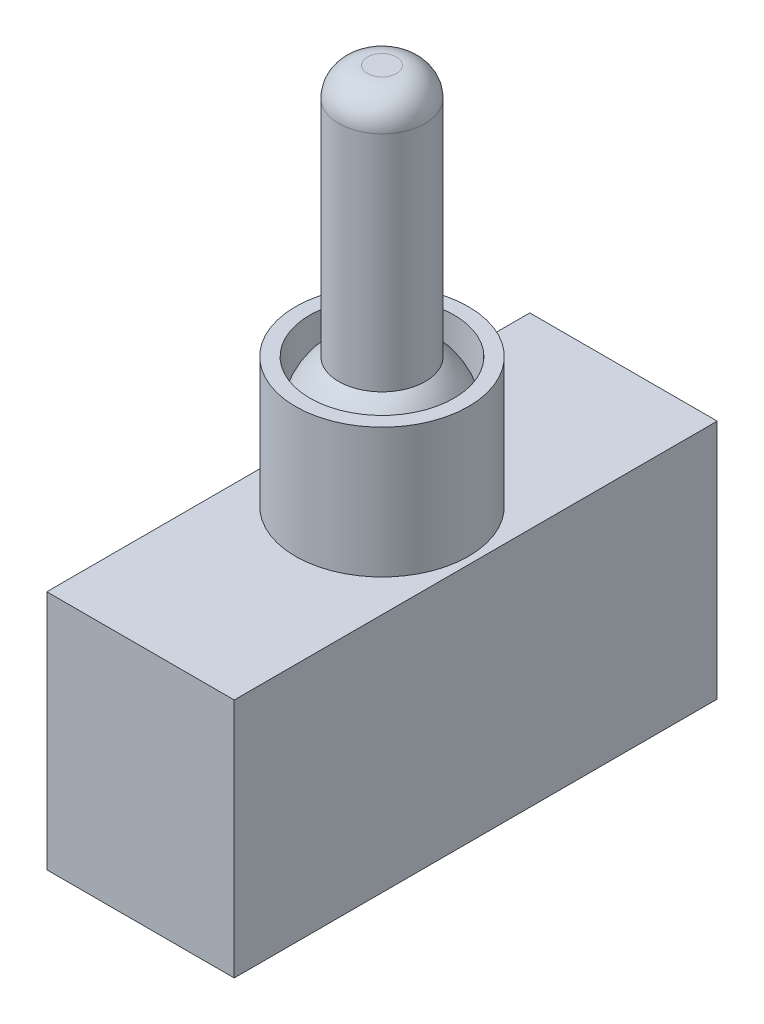
from build123d import *

# Parameters (mm, degrees)
SKETCH1_W           = 13
SKETCH1_H           = 33.5
BOSS_EXTRUDE1_DEPTH = 16.7
SKETCH2_R           = 6
BOSS_EXTRUDE2_DEPTH = 9
SKETCH4_R           = 5
CUT_EXTRUDE1_DEPTH  = 4
SKETCH5_R           = 3
BOSS_EXTRUDE3_DEPTH = 21.5
REVOLVE2_ANGLE      = 180
FILLET1_R           = 2


with BuildPart() as part:
    # Sketch1 → Boss-Extrude1 (new body)
    with BuildSketch(Plane(origin=(0, 0, 0), x_dir=(1, 0, 0), z_dir=(0, 1, 0))):
        Rectangle(SKETCH1_W, SKETCH1_H)
    extrude(amount=BOSS_EXTRUDE1_DEPTH)

    # Sketch2 → Boss-Extrude2 (add)
    with BuildSketch(Plane(origin=(0, 16.7, 0), x_dir=(1, 0, 0), z_dir=(0, 1, 0))):
        with Locations(Location((0, 0, 0), (0, 0, 270))):  # turned: the seam where the file's is
            Circle(SKETCH2_R)
    extrude(amount=BOSS_EXTRUDE2_DEPTH)

    # Sketch4 → Cut-Extrude1 (cut)
    with BuildSketch(Plane(origin=(0, 25.7, 0), x_dir=(1, 0, 0), z_dir=(0, 1, 0))):
        with Locations(Location((0, 0, 0), (0, 0, 270))):  # turned: the seam where the file's is
            Circle(SKETCH4_R)
    extrude(amount=-CUT_EXTRUDE1_DEPTH, mode=Mode.SUBTRACT)

    # Sketch5 → Boss-Extrude3 (add)
    with BuildSketch(Plane(origin=(0, 21.7, 0), x_dir=(1, 0, 0), z_dir=(0, 1, 0))):
        with Locations(Location((0, 0, 0), (0, 0, 270))):  # turned: the seam where the file's is
            Circle(SKETCH5_R)
    extrude(amount=BOSS_EXTRUDE3_DEPTH)

    # Sketch3 → Revolve2 (revolve)
    with BuildSketch(Plane(origin=(0, 21.7, 0), x_dir=(1, 0, 0), z_dir=(0, 1, 0))):
        with BuildLine():
            Line((0, -5), (0, 5))
            ThreePointArc((0, 5), (-5, 0), (0, -5))
        make_face()
    revolve(axis=Axis((0, 21.7, 6), (0, 0, -1)), revolution_arc=REVOLVE2_ANGLE)

    # Fillet1
    fillet1_edges = [part.edges().sort_by_distance(p)[0] for p in [
        (0, 43.2, -3),
    ]]
    fillet(fillet1_edges, radius=FILLET1_R)


solid = part.part
